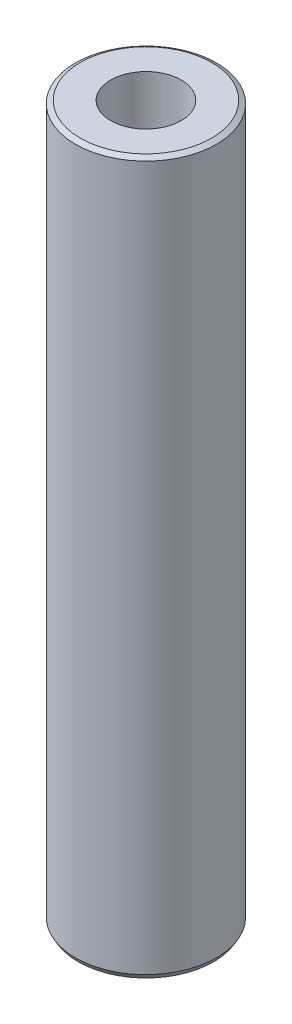
from build123d import *

# Parameters (mm, degrees)
SKETCH2_R             = 2.5
BOSS_EXTRUDE1_DEPTH   = 25.25
CHAMFER1_SIZE         = 0.1
CHAMFER1_SIZE2        = 0.173205081
CHAMFER1_PART_2_SIZE  = 0.1
CHAMFER1_PART_2_SIZE2 = 0.173205081
M3X0_5_TAPPED_HOLE1_D = 2.5


with BuildPart() as part:
    # Sketch2 → Boss-Extrude1 (new body)
    with BuildSketch(Plane(origin=(0, 0, 0), x_dir=(1, 0, 0), z_dir=(0, 1, 0))):
        Circle(SKETCH2_R)
    extrude(amount=BOSS_EXTRUDE1_DEPTH)

    # Chamfer1
    chamfer1_edges = [part.edges().sort_by_distance(p)[0] for p in [
        (-2.5, 0, 0),
    ]]
    chamfer1_side = [part.faces().sort_by_distance(p)[0] for p in [
        (0, 0, 0),
    ]]
    chamfer(chamfer1_edges, length=CHAMFER1_SIZE, length2=CHAMFER1_SIZE2, reference=chamfer1_side[0])

    # Chamfer1 part 2
    chamfer1_part_2_edges = [part.edges().sort_by_distance(p)[0] for p in [
        (-2.5, 25.25, 0),
    ]]
    chamfer1_part_2_side = [part.faces().sort_by_distance(p)[0] for p in [
        (-2.5, 12.625, 0),
    ]]
    chamfer(chamfer1_part_2_edges, length=CHAMFER1_PART_2_SIZE, length2=CHAMFER1_PART_2_SIZE2, reference=chamfer1_part_2_side[0])

    # M3x0.5 Tapped Hole1 (through all)
    with Locations(Plane(origin=(0, 25.25, 0), x_dir=(1, 0, 0), z_dir=(0, 1, 0))):
        with Locations((0, 0)):
            Hole(M3X0_5_TAPPED_HOLE1_D / 2)


solid = part.part
